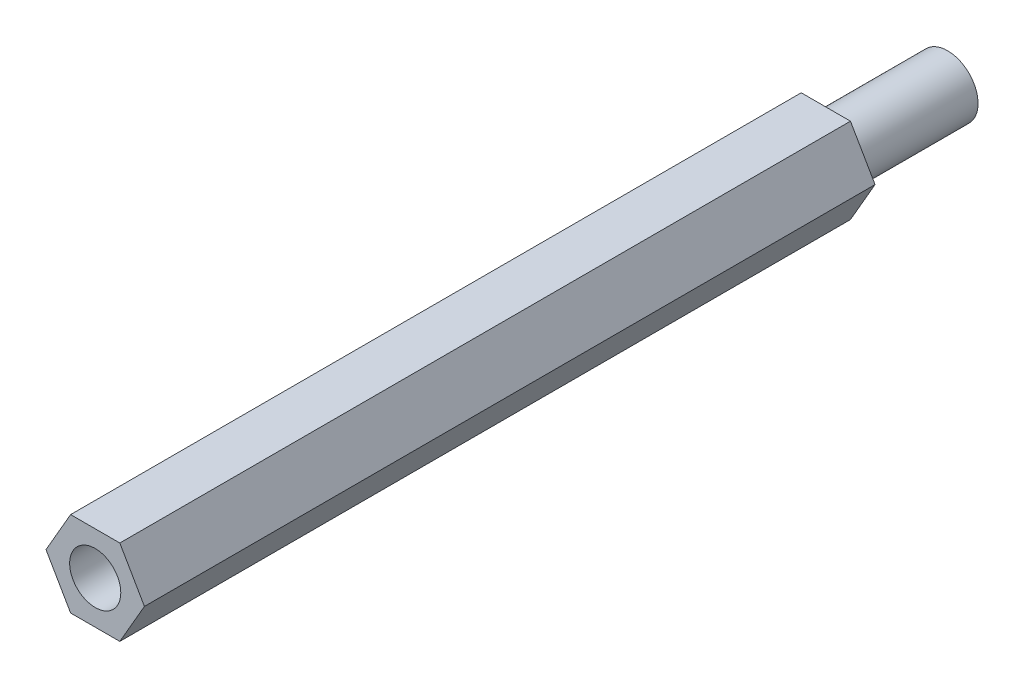
from build123d import *

# Parameters (mm, degrees)
EXTRUDE_1_DEPTH           = 60
SKETCH_4_R                = 2.5
EXTRUDE_2_DEPTH           = 10
M5X0_8_TAPPED_HOLE1_D     = 4.2
M5X0_8_TAPPED_HOLE1_DEPTH = 12.4
M5X0_8_TAPPED_HOLE1_TIP   = 1.2618073


with BuildPart() as part:
    # 草圖1 → 填料-伸長1 (new body)
    with BuildSketch(Plane.XY):
        Polygon((-2.020725942, 3.5), (-4.041451884, 0), (-2.020725942, -3.5), (2.020725942, -3.5), (4.041451884, 0), (2.020725942, 3.5), align=None)
    extrude(amount=EXTRUDE_1_DEPTH)

    # 草圖4 → 填料-伸長2 (add)
    with BuildSketch(Plane(origin=(0, 0, 0), x_dir=(-1, 0, 0), z_dir=(0, 0, -1))):
        Circle(SKETCH_4_R)
    extrude(amount=EXTRUDE_2_DEPTH)

    # M5x0.8 Tapped Hole1
    with Locations(Plane.XY.offset(60)):
        with Locations((0, 0)):
            Hole(M5X0_8_TAPPED_HOLE1_D / 2, depth=M5X0_8_TAPPED_HOLE1_DEPTH)
            with Locations((0, 0, -(M5X0_8_TAPPED_HOLE1_DEPTH + M5X0_8_TAPPED_HOLE1_TIP / 2))):  # 118° drill point
                Cone(0, M5X0_8_TAPPED_HOLE1_D / 2, M5X0_8_TAPPED_HOLE1_TIP, mode=Mode.SUBTRACT)


solid = part.part
